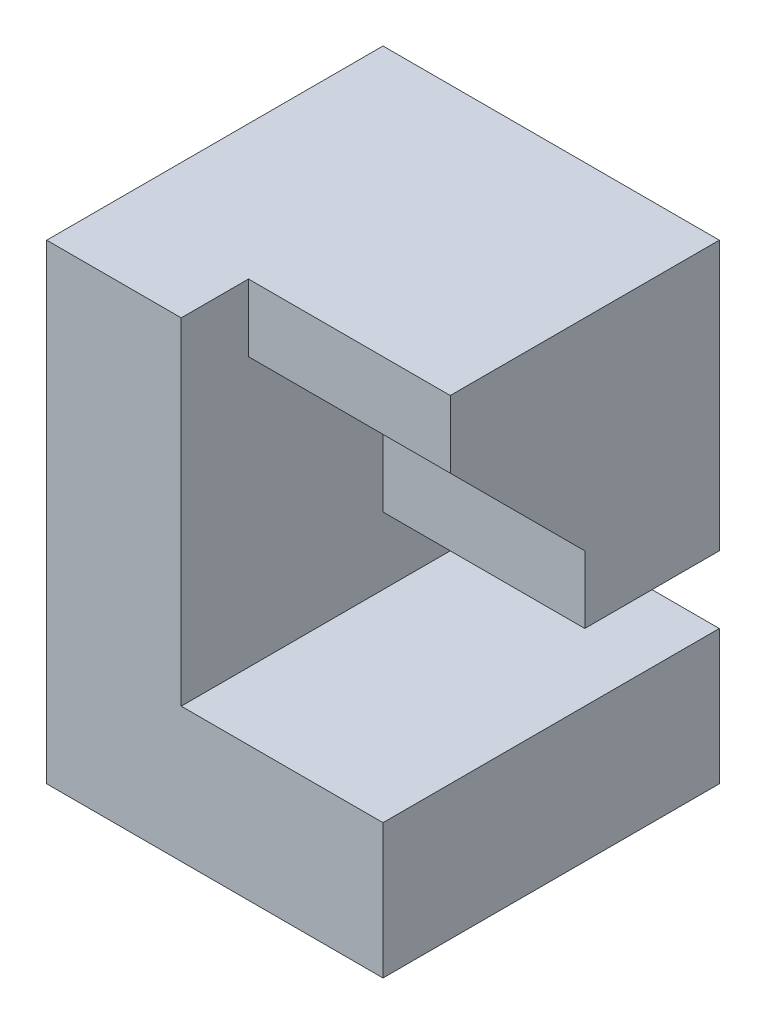
from build123d import *

# Parameters (mm, degrees)
SKETCH1_W           = 5
SKETCH1_H           = 7
BOSS_EXTRUDE1_DEPTH = 5
CUT_EXTRUDE1_DEPTH  = 3


with BuildPart() as part:
    # Sketch1 → Boss-Extrude1 (new body)
    with BuildSketch(Plane(origin=(0, 0, 0), x_dir=(0, 0, -1), z_dir=(1, 0, 0))):
        Rectangle(SKETCH1_W, SKETCH1_H)
    extrude(amount=BOSS_EXTRUDE1_DEPTH)

    # Sketch2 → Cut-Extrude1 (cut)
    with BuildSketch(Plane(origin=(5, 0, 0), x_dir=(0, 0, -1), z_dir=(1, 0, 0))):
        Polygon((2.5, -1.5), (-2.5, -1.5), (-2.5, 3.5), (-1.5, 3.5), (-1.5, 2.5), (0.5, 0.5), (0.5, -0.5), (2.5, -0.5), align=None)
    extrude(amount=-CUT_EXTRUDE1_DEPTH, mode=Mode.SUBTRACT)


solid = part.part
